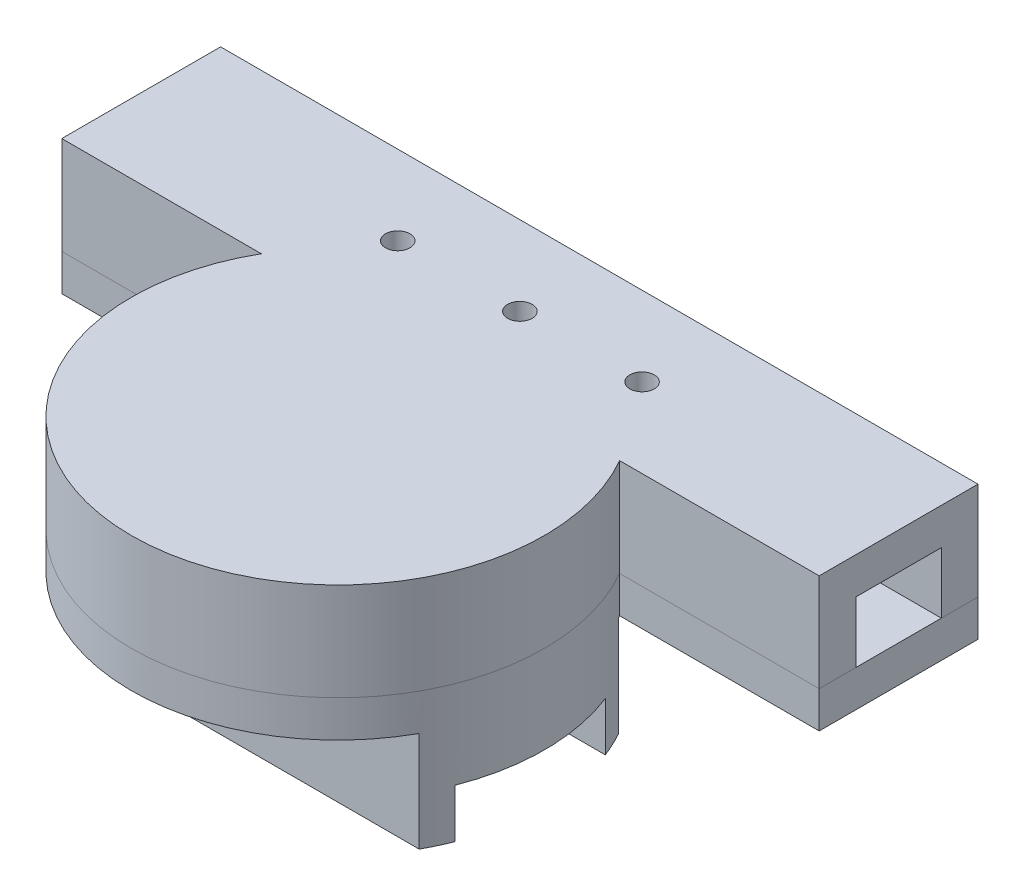
from build123d import *

# Parameters (mm, degrees)
BOSS_EXTRUDE1_DEPTH      = 5
SKETCH1_W                = 6
SKETCH1_H                = 3
BOSS_EXTRUDE1_2_DEPTH    = 5
BOSS_EXTRUDE1_3_DEPTH    = 5
BOSS_EXTRUDE2_START      = 3
SKETCH1_4_R              = 2
BOSS_EXTRUDE2_DEPTH      = 3
BOSS_EXTRUDE6_DEPTH      = 3
BOSS_EXTRUDE6_DEPTH_BACK = 2
SKETCH1_7_R              = 2
SKETCH3_W                = 50
SKETCH3_H                = 3
BOSS_EXTRUDE7_DEPTH      = 3
SKETCH5_R                = 1
CUT_EXTRUDE1_DEPTH       = 6
CUT_EXTRUDE2_DEPTH       = 2.2
CUT_EXTRUDE2_DEPTH_BACK  = 1
SKETCH6_R                = 2
SKETCH1_9_W              = 50
SKETCH1_9_H              = 3
BOSS_EXTRUDE9_DEPTH      = 1.6
SKETCH3_5_R              = 5.35
CUT_EXTRUDE3_DEPTH       = 5
SKETCH11_R               = 0.75
CUT_EXTRUDE5_DEPTH       = 6
BOSS_EXTRUDE11_DEPTH     = 4.2
BOSS_EXTRUDE12_DEPTH     = 4
SKETCH11_4_R             = 1.25
SKETCH11_4_R_2           = 0.75
CUT_EXTRUDE6_DEPTH       = 1


with BuildPart() as part:
    # Sketch1 → Boss-Extrude1 (new body)
    with BuildSketch(Plane(origin=(0, 0, 0), x_dir=(1, 0, 0), z_dir=(0, 1, 0))):
        with BuildLine():
            Line((-31, 11.397780108), (-31, 8.397780108))
            Line((-31, 8.397780108), (-14.665854535, 8.397780108))
            ThreePointArc((-14.665854535, 8.397780108), (0, -16.9), (14.665854535, 8.397780108))
            Line((14.665854535, 8.397780108), (31, 8.397780108))
            Line((31, 8.397780108), (31, 11.397780108))
            Line((31, 11.397780108), (7.956167959, 11.397780108))
            ThreePointArc((7.956167959, 11.397780108), (0, -13.9), (-7.956167959, 11.397780108))
            Line((-7.956167959, 11.397780108), (-31, 11.397780108))
        make_face()
    extrude(amount=-BOSS_EXTRUDE1_DEPTH)



with BuildPart() as body_2:
    # Sketch1 → Boss-Extrude1 2 (new body)
    with BuildSketch(Plane(origin=(0, 0, 0), x_dir=(1, 0, 0), z_dir=(0, 1, 0))):
        with Locations((-28, 19.897780108)):
            Rectangle(SKETCH1_W, SKETCH1_H)
    extrude(amount=-BOSS_EXTRUDE1_2_DEPTH)


with BuildPart() as body_3:
    # Sketch1 → Boss-Extrude1 3 (new body)
    with BuildSketch(Plane(origin=(0, 0, 0), x_dir=(1, 0, 0), z_dir=(0, 1, 0))):
        with Locations((28, 19.897780108)):
            Rectangle(SKETCH1_W, SKETCH1_H)
    extrude(amount=-BOSS_EXTRUDE1_3_DEPTH)


with BuildPart() as part_1:
    add(part.part)

    add(body_2.part)  # Boss-Extrude2 merges body 2

    add(body_3.part)  # Boss-Extrude2 merges body 3
    # Sketch1_4 → Boss-Extrude2 (add)
    with BuildSketch(Plane(origin=(0, 0, 0), x_dir=(1, 0, 0), z_dir=(0, 1, 0)).offset(BOSS_EXTRUDE2_START)):
        with BuildLine():
            Line((-31, 8.397780108), (-14.665854535, 8.397780108))
            ThreePointArc((-14.665854535, 8.397780108), (0, -16.9), (14.665854535, 8.397780108))
            Line((14.665854535, 8.397780108), (31, 8.397780108))
            Line((31, 8.397780108), (31, 21.397780108))
            Line((31, 21.397780108), (-31, 21.397780108))
            Line((-31, 21.397780108), (-31, 8.397780108))
        make_face()
        Circle(SKETCH1_4_R, mode=Mode.SUBTRACT)
    extrude(amount=-BOSS_EXTRUDE2_DEPTH)

    # Sketch1_7 → Boss-Extrude6 (add, two sides: drawn at the far end of the back side and taken through both)
    with BuildSketch(Plane(origin=(0, 0, 0), x_dir=(1, 0, 0), z_dir=(0, 1, 0)).offset(-BOSS_EXTRUDE6_DEPTH_BACK)):
        Circle(SKETCH1_7_R)
    extrude(amount=BOSS_EXTRUDE6_DEPTH + BOSS_EXTRUDE6_DEPTH_BACK)

    # Sketch5 → Cut-Extrude1 (cut)
    with BuildSketch(Plane(origin=(0, 3, 0), x_dir=(1, 0, 0), z_dir=(0, 1, 0))):
        with Locations((0, 14.897780108)):
            Circle(SKETCH5_R)
        with Locations((10, 14.897780108)):
            Circle(SKETCH5_R)
        with Locations((-10, 14.897780108)):
            Circle(SKETCH5_R)
    extrude(amount=-CUT_EXTRUDE1_DEPTH, mode=Mode.SUBTRACT)

    # Sketch6 → Cut-Extrude2 (cut, two sides: drawn at the far end of the back side and taken through both)
    with BuildSketch(Plane.XZ.offset(-CUT_EXTRUDE2_DEPTH_BACK)):
        with Locations((-10, -14.897780108)):
            Circle(SKETCH6_R)
        with Locations((0, -14.897780108)):
            Circle(SKETCH6_R)
        with Locations((10, -14.897780108)):
            Circle(SKETCH6_R)
    extrude(amount=CUT_EXTRUDE2_DEPTH + CUT_EXTRUDE2_DEPTH_BACK, mode=Mode.SUBTRACT)

    # Sketch1_9 → Boss-Extrude9 (add)
    with BuildSketch(Plane(origin=(0, 0, 0), x_dir=(1, 0, 0), z_dir=(0, 1, 0))):
        with Locations((0, 19.897780108)):
            Rectangle(SKETCH1_9_W, SKETCH1_9_H)
    extrude(amount=-BOSS_EXTRUDE9_DEPTH)


with BuildPart() as body_2_2:
    # Sketch3 → Boss-Extrude7 (new body)
    with BuildSketch(Plane.XZ.offset(5)):
        with BuildLine():
            Line((31, -8.397780108), (14.665854535, -8.397780108))
            ThreePointArc((14.665854535, -8.397780108), (0, 16.9), (-14.665854535, -8.397780108))
            Line((-14.665854535, -8.397780108), (-31, -8.397780108))
            Line((-31, -8.397780108), (-31, -21.397780108))
            Line((-31, -21.397780108), (31, -21.397780108))
            Line((31, -21.397780108), (31, -8.397780108))
        make_face()
        with Locations((0, -14.897780108)):
            Rectangle(SKETCH3_W, SKETCH3_H, mode=Mode.SUBTRACT)
    extrude(amount=BOSS_EXTRUDE7_DEPTH)

    # Sketch3_5 → Cut-Extrude3 (cut)
    with BuildSketch(Plane.XZ.offset(5)):
        Circle(SKETCH3_5_R)
    extrude(amount=CUT_EXTRUDE3_DEPTH, mode=Mode.SUBTRACT)


with BuildPart() as cut_extrude5_tool:
    # Sketch11 → Cut-Extrude5 (new body)
    with BuildSketch(Plane.XZ.offset(8)):
        with Locations((-28.07299319, -9.897780108)):
            Circle(SKETCH11_R)
        with Locations((27.855473314, -9.897780108)):
            Circle(SKETCH11_R)
        with Locations((27.855473314, -19.897780108)):
            Circle(SKETCH11_R)
        with Locations((-28.07299319, -19.897780108)):
            Circle(SKETCH11_R)
        with Locations((0, 15.271275141)):
            Circle(SKETCH11_R)
    extrude(amount=-CUT_EXTRUDE5_DEPTH)


with BuildPart() as part_2:
    add(part_1.part)

    # Cut-Extrude5: cut by cut_extrude5_tool
    add(cut_extrude5_tool.part, mode=Mode.SUBTRACT)


with BuildPart() as body_2_2_1:
    add(body_2_2.part)

    # Cut-Extrude5: cut by cut_extrude5_tool
    add(cut_extrude5_tool.part, mode=Mode.SUBTRACT)

    # Sketch12 → Boss-Extrude11 (add)
    with BuildSketch(Plane.XZ.offset(8)):
        with BuildLine():
            Line((-10.75, -8.15), (14.804982269, -8.15))
            ThreePointArc((14.804982269, -8.15), (16.9, 0), (14.804982269, 8.15))
            Line((14.804982269, 8.15), (-10.75, 8.15))
            Line((-10.75, 8.15), (-10.75, 0.49803322))
            Line((-10.75, 0.49803322), (-9.895643924, 0.49803322))
            ThreePointArc((-9.895643924, 0.49803322), (-7.5, -0.00196678), (-9.895643924, -0.50196678))
            Line((-9.895643924, -0.50196678), (-10.75, -0.50196678))
            Line((-10.75, -0.50196678), (-10.75, -8.15))
        make_face()
        with BuildLine():
            Line((5.423329236, 2.9), (5.75, 2.9))
            ThreePointArc((5.75, 2.9), (8.65, 0), (5.75, -2.9))
            Line((5.75, -2.9), (5.423329236, -2.9))
            ThreePointArc((5.423329236, -2.9), (-6.15, 0), (5.423329236, 2.9))
        make_face(mode=Mode.SUBTRACT)
    extrude(amount=BOSS_EXTRUDE11_DEPTH)

    # Sketch13 → Boss-Extrude12 (add)
    with BuildSketch(Plane.XZ.offset(12.2)):
        with BuildLine():
            Line((-10.75, -8.15), (14.804982269, -8.15))
            ThreePointArc((14.804982269, -8.15), (15.305827078, -7.165309307), (15.74126742, -6.15))
            Line((15.74126742, -6.15), (6e-09, -6.15))
            ThreePointArc((6e-09, -6.15), (-6.15, -3e-09), (0, 6.15))
            Line((0, 6.15), (15.74126742, 6.15))
            ThreePointArc((15.74126742, 6.15), (15.305827078, 7.165309307), (14.804982269, 8.15))
            Line((14.804982269, 8.15), (-10.75, 8.15))
            Line((-10.75, 8.15), (-10.75, 0.49803322))
            Line((-10.75, 0.49803322), (-9.895643924, 0.49803322))
            ThreePointArc((-9.895643924, 0.49803322), (-7.5, -0.00196678), (-9.895643924, -0.50196678))
            Line((-9.895643924, -0.50196678), (-10.75, -0.50196678))
            Line((-10.75, -0.50196678), (-10.75, -8.15))
        make_face()
    extrude(amount=BOSS_EXTRUDE12_DEPTH)

    # Sketch11_4 → Cut-Extrude6 (cut)
    # profile 1 of 5: a face of its own
    with BuildSketch(Plane.XZ.offset(8)):
        with Locations((27.855473314, -19.897780108)):
            Circle(SKETCH11_4_R)
        with Locations((27.855473314, -19.897780108)):
            Circle(SKETCH11_4_R_2, mode=Mode.SUBTRACT)
    # profile 2 of 5: a face of its own
    with BuildSketch(Plane.XZ.offset(8)):
        with Locations((27.855473314, -9.897780108)):
            Circle(SKETCH11_4_R)
        with Locations((27.855473314, -9.897780108)):
            Circle(SKETCH11_4_R_2, mode=Mode.SUBTRACT)
    # profile 3 of 5: a face of its own
    with BuildSketch(Plane.XZ.offset(8)):
        with Locations((-28.07299319, -19.897780108)):
            Circle(SKETCH11_4_R)
        with Locations((-28.07299319, -19.897780108)):
            Circle(SKETCH11_4_R_2, mode=Mode.SUBTRACT)
    # profile 4 of 5: a face of its own
    with BuildSketch(Plane.XZ.offset(8)):
        with Locations((-28.07299319, -9.897780108)):
            Circle(SKETCH11_4_R)
        with Locations((-28.07299319, -9.897780108)):
            Circle(SKETCH11_4_R_2, mode=Mode.SUBTRACT)
    # profile 5 of 5: a face of its own
    with BuildSketch(Plane.XZ.offset(8)):
        with Locations((0, 15.271275141)):
            Circle(SKETCH11_4_R)
        with Locations((0, 15.271275141)):
            Circle(SKETCH11_4_R_2, mode=Mode.SUBTRACT)
    extrude(amount=-CUT_EXTRUDE6_DEPTH, mode=Mode.SUBTRACT)


solid = Compound([part_2.part, body_2_2_1.part])
